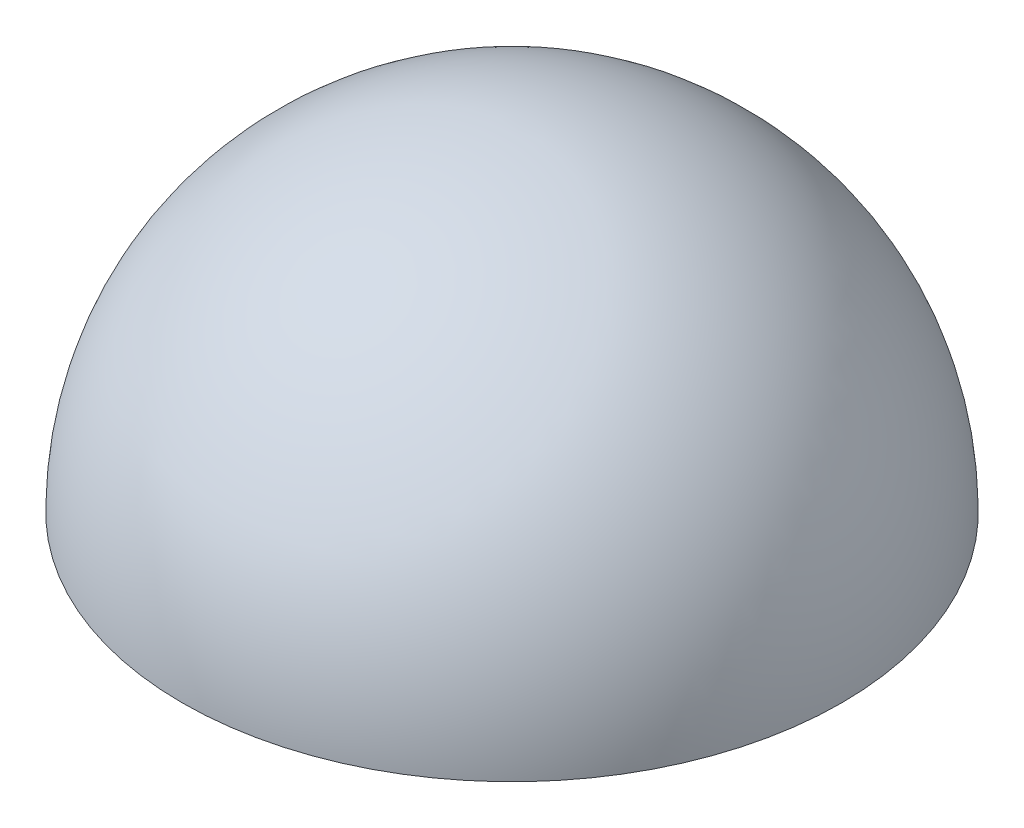
from build123d import *

# Parameters (mm, degrees)
SKETCH9_R          = 5
CUT_EXTRUDE1_DEPTH = 5


with BuildPart() as part:
    # Sketch8 → Revolve5 (revolve)
    with BuildSketch(Plane.XY):
        with BuildLine():
            Line((0, 5), (0, -5))
            ThreePointArc((0, -5), (5, 0), (0, 5))
        make_face()
    revolve(axis=Axis((0, -5, 0), (0, 1, 0)))

    # Sketch9 → Cut-Extrude1 (cut)
    with BuildSketch(Plane(origin=(0, 0, 0), x_dir=(1, 0, 0), z_dir=(0, 1, 0))):
        Circle(SKETCH9_R)
    extrude(amount=-CUT_EXTRUDE1_DEPTH, mode=Mode.SUBTRACT)


solid = part.part
